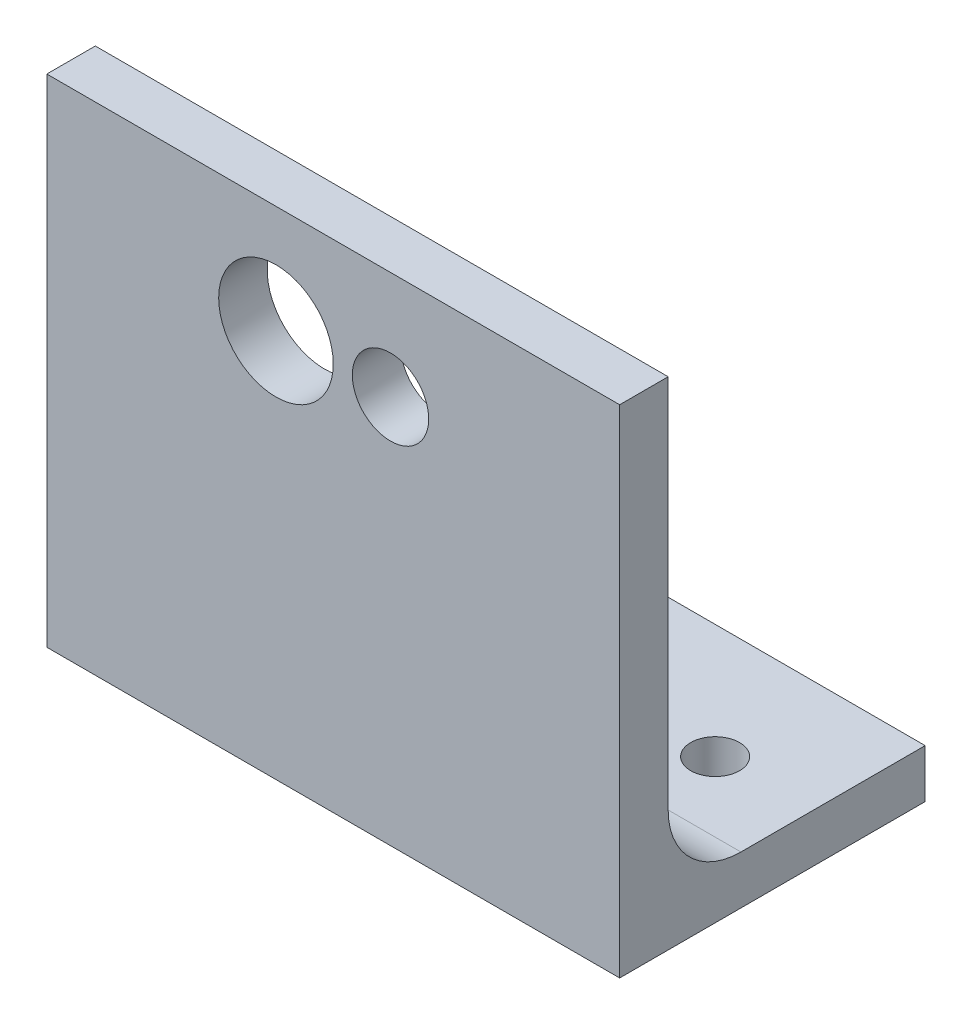
from build123d import *

# Parameters (mm, degrees)
BOSS_EXTRUDE1_DEPTH  = 75
SKETCH2_R            = 7.5
SKETCH2_R_2          = 5
SKETCH2_W            = 75
SKETCH2_H            = 23.9
CUT_EXTRUDE1_DEPTH   = 75
M6_CLEARANCE_HOLE1_D = 6.4


with BuildPart() as part:
    # Sketch1 → Boss-Extrude1 (new body)
    with BuildSketch(Plane(origin=(0, 0, 0), x_dir=(0, 0, -1), z_dir=(1, 0, 0))):
        with BuildLine():
            Line((0, 0), (0, 88.9))
            Line((0, 88.9), (6.35, 88.9))
            Line((6.35, 88.9), (6.35, 15.875))
            ThreePointArc((6.35, 15.875), (9.139807909, 9.139807909), (15.875, 6.35))
            Line((15.875, 6.35), (40, 6.35))
            Line((40, 6.35), (40, 0))
            Line((40, 0), (0, 0))
        make_face()
    extrude(amount=BOSS_EXTRUDE1_DEPTH)

    # Sketch2 → Cut-Extrude1 (cut)
    with BuildSketch(Plane(origin=(0, 0, 0), x_dir=(-1, 0, 0), z_dir=(0, 0, -1))):
        with Locations((-30, 50.875)):
            Circle(SKETCH2_R)
        with Locations((-45, 50.875)):
            Circle(SKETCH2_R_2)
        with Locations((-37.5, 76.95)):
            Rectangle(SKETCH2_W, SKETCH2_H)
    extrude(amount=CUT_EXTRUDE1_DEPTH, mode=Mode.SUBTRACT)

    # M6 Clearance Hole1 (through all)
    with Locations(Plane(origin=(12.5, 0, -25), x_dir=(0, 0, -1), z_dir=(0, -1, 0))):
        with Locations((0, 0), (0, 50)):
            Hole(M6_CLEARANCE_HOLE1_D / 2)


solid = part.part
